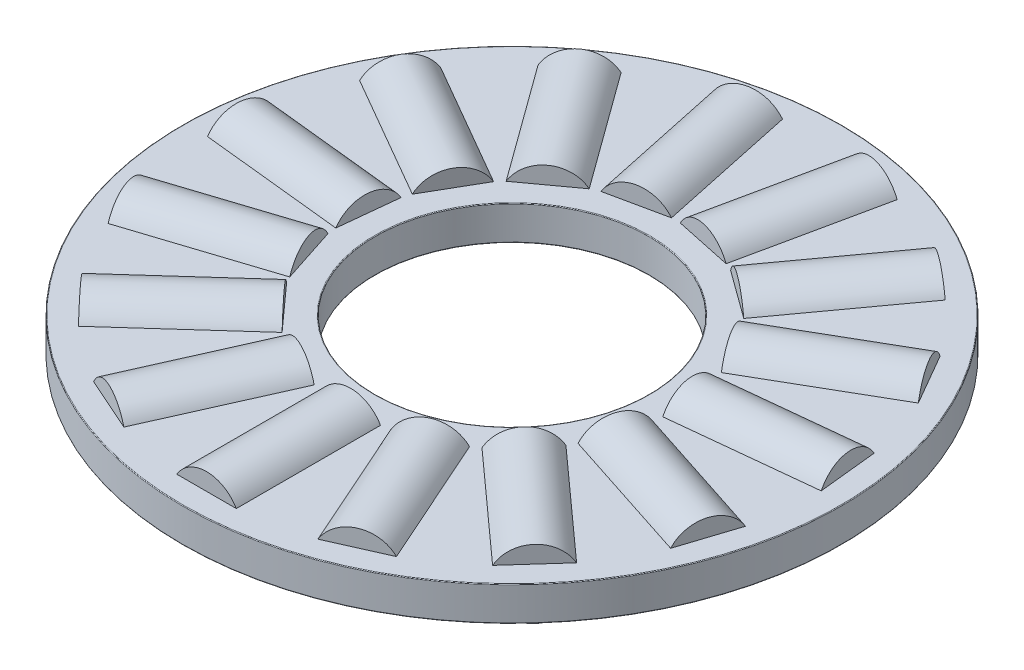
from build123d import *

# Parameters (mm, degrees)
SKETCH1_W         = 5.5626
SKETCH1_H         = 0.9921875
SKETCH3_W         = 4.1671875
SKETCH3_H         = 0.9921875
SKETCH2_W         = 4.1671875
SKETCH2_H         = 0.9921875
CIRPATTERN1_COUNT = 15
CIRPATTERN1_ANGLE = 336
CIRPATTERN2_COUNT = 15
FILLET2_R         = 0.01984375


with BuildPart() as part:
    # Sketch1 → Revolve1 (revolve)
    with BuildSketch(Plane(origin=(0, 0, 0), x_dir=(0, 0, -1), z_dir=(1, 0, 0)), mode=Mode.PRIVATE) as revolve1_sk:
        with Locations((-6.7437, 0)):
            Rectangle(SKETCH1_W, SKETCH1_H)
    revolve(revolve1_sk.sketch.rotate(Axis((0, -0.9921875, 0), (0, 1, 0)), 180), axis=Axis((0, -0.9921875, 0), (0, 1, 0)))

    # Sketch3 → Cut-Revolve1 (revolve, cut)
    with BuildSketch(Plane(origin=(0, 0, 0), x_dir=(0, 0, -1), z_dir=(1, 0, 0))):
        with Locations((-6.7437, 0.49609375)):
            Rectangle(SKETCH3_W, SKETCH3_H)
    cut_revolve1 = revolve(axis=Axis((0, 0, 8.82729375), (0, 0, -1)), mode=Mode.SUBTRACT)

    # CirPattern2: Cut-Revolve1 ×15 about axis
    cirpattern2_axis = Axis((0, 0, 0), (0, 1, 0))
    for i in range(1, CIRPATTERN2_COUNT):
        add(cut_revolve1.rotate(cirpattern2_axis, i * 360 / CIRPATTERN2_COUNT), mode=Mode.SUBTRACT)

    # Fillet2
    fillet2_edges = [part.edges().sort_by_distance(p)[0] for p in [
        (0, 0.49609375, 9.525),
        (0, 0.49609375, 3.9624),
        (0, -0.49609375, 3.9624),
        (0, -0.49609375, 9.525),
    ]]
    fillet(fillet2_edges, radius=FILLET2_R)


with BuildPart() as body_2:
    # Sketch2 → Revolve2 (revolve)
    with BuildSketch(Plane(origin=(0, 0, 0), x_dir=(0, 0, -1), z_dir=(1, 0, 0)), mode=Mode.PRIVATE) as revolve2_sk:
        with Locations((-6.7437, 0.49609375)):
            Rectangle(SKETCH2_W, SKETCH2_H)
    revolve(revolve2_sk.sketch.rotate(Axis((0, 0, 8.82729375), (0, 0, -1)), 90), axis=Axis((0, 0, 8.82729375), (0, 0, -1)))


with BuildPart() as cirpattern1_1:
    # CirPattern1: pattern copy
    add(body_2.part.rotate(Axis((0, 0.9921875, 0), (0, -1, 0)), 1 * CIRPATTERN1_ANGLE / (CIRPATTERN1_COUNT - 1)))


with BuildPart() as cirpattern1_2:
    # CirPattern1: pattern copy
    add(body_2.part.rotate(Axis((0, 0.9921875, 0), (0, -1, 0)), 2 * CIRPATTERN1_ANGLE / (CIRPATTERN1_COUNT - 1)))


with BuildPart() as cirpattern1_3:
    # CirPattern1: pattern copy
    add(body_2.part.rotate(Axis((0, 0.9921875, 0), (0, -1, 0)), 3 * CIRPATTERN1_ANGLE / (CIRPATTERN1_COUNT - 1)))


with BuildPart() as cirpattern1_4:
    # CirPattern1: pattern copy
    add(body_2.part.rotate(Axis((0, 0.9921875, 0), (0, -1, 0)), 4 * CIRPATTERN1_ANGLE / (CIRPATTERN1_COUNT - 1)))


with BuildPart() as cirpattern1_5:
    # CirPattern1: pattern copy
    add(body_2.part.rotate(Axis((0, 0.9921875, 0), (0, -1, 0)), 5 * CIRPATTERN1_ANGLE / (CIRPATTERN1_COUNT - 1)))


with BuildPart() as cirpattern1_6:
    # CirPattern1: pattern copy
    add(body_2.part.rotate(Axis((0, 0.9921875, 0), (0, -1, 0)), 6 * CIRPATTERN1_ANGLE / (CIRPATTERN1_COUNT - 1)))


with BuildPart() as cirpattern1_7:
    # CirPattern1: pattern copy
    add(body_2.part.rotate(Axis((0, 0.9921875, 0), (0, -1, 0)), 7 * CIRPATTERN1_ANGLE / (CIRPATTERN1_COUNT - 1)))


with BuildPart() as cirpattern1_8:
    # CirPattern1: pattern copy
    add(body_2.part.rotate(Axis((0, 0.9921875, 0), (0, -1, 0)), 8 * CIRPATTERN1_ANGLE / (CIRPATTERN1_COUNT - 1)))


with BuildPart() as cirpattern1_9:
    # CirPattern1: pattern copy
    add(body_2.part.rotate(Axis((0, 0.9921875, 0), (0, -1, 0)), 9 * CIRPATTERN1_ANGLE / (CIRPATTERN1_COUNT - 1)))


with BuildPart() as cirpattern1_10:
    # CirPattern1: pattern copy
    add(body_2.part.rotate(Axis((0, 0.9921875, 0), (0, -1, 0)), 10 * CIRPATTERN1_ANGLE / (CIRPATTERN1_COUNT - 1)))


with BuildPart() as cirpattern1_11:
    # CirPattern1: pattern copy
    add(body_2.part.rotate(Axis((0, 0.9921875, 0), (0, -1, 0)), 11 * CIRPATTERN1_ANGLE / (CIRPATTERN1_COUNT - 1)))


with BuildPart() as cirpattern1_12:
    # CirPattern1: pattern copy
    add(body_2.part.rotate(Axis((0, 0.9921875, 0), (0, -1, 0)), 12 * CIRPATTERN1_ANGLE / (CIRPATTERN1_COUNT - 1)))


with BuildPart() as cirpattern1_13:
    # CirPattern1: pattern copy
    add(body_2.part.rotate(Axis((0, 0.9921875, 0), (0, -1, 0)), 13 * CIRPATTERN1_ANGLE / (CIRPATTERN1_COUNT - 1)))


with BuildPart() as cirpattern1_14:
    # CirPattern1: pattern copy
    add(body_2.part.rotate(Axis((0, 0.9921875, 0), (0, -1, 0)), 14 * CIRPATTERN1_ANGLE / (CIRPATTERN1_COUNT - 1)))


solid = Compound([part.part, body_2.part, cirpattern1_1.part, cirpattern1_2.part, cirpattern1_3.part, cirpattern1_4.part, cirpattern1_5.part, cirpattern1_6.part, cirpattern1_7.part, cirpattern1_8.part, cirpattern1_9.part, cirpattern1_10.part, cirpattern1_11.part, cirpattern1_12.part, cirpattern1_13.part, cirpattern1_14.part])
